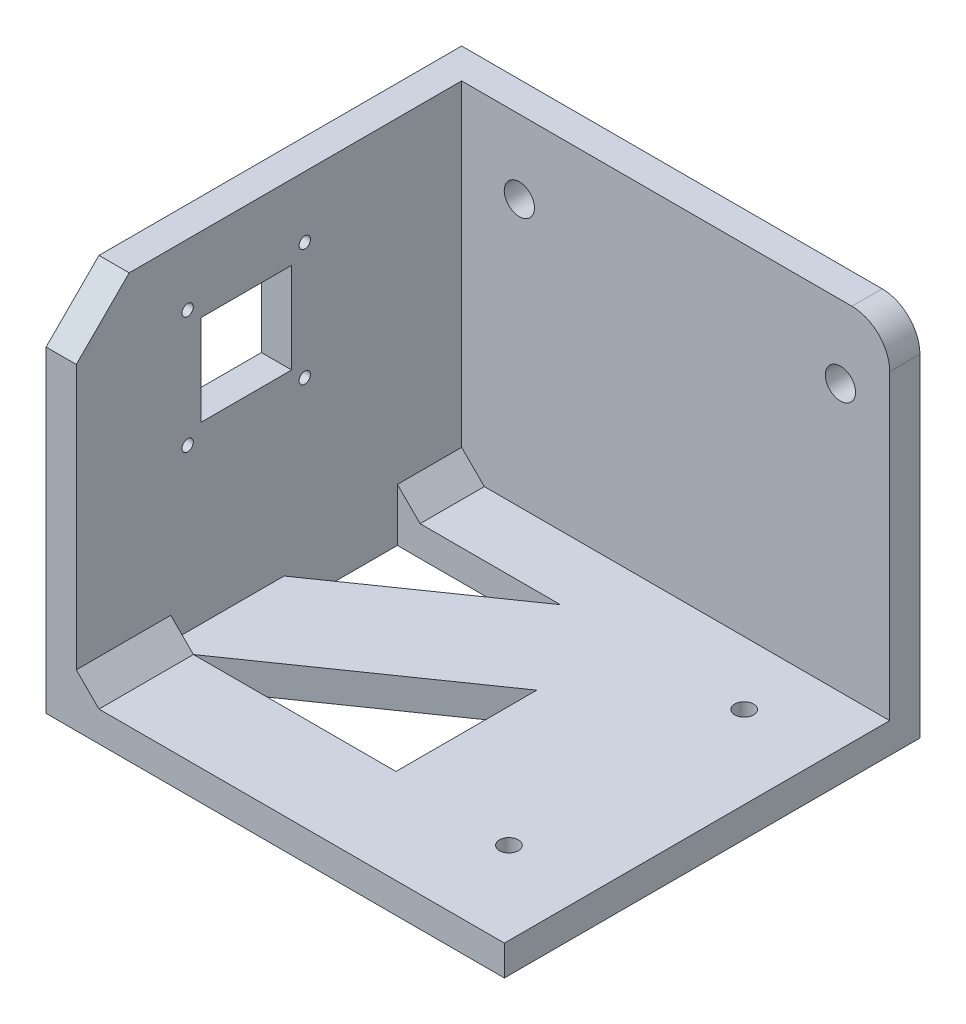
from build123d import *

# Parameters (mm, degrees)
SKETCH2_W            = 45
SKETCH2_H            = 45
BOSS_EXTRUDE1_DEPTH  = 4
SKETCH3_R            = 0.75
CUT_EXTRUDE1_DEPTH   = 5
SKETCH4_W            = 12
SKETCH4_H            = 12
CUT_EXTRUDE2_DEPTH   = 5
SKETCH5_W            = 55
SKETCH5_H            = 4
BOSS_EXTRUDE2_DEPTH  = 60.654134022
SKETCH7_W            = 4
SKETCH7_H            = 49
BOSS_EXTRUDE3_DEPTH  = 10
CUT_EXTRUDE6_DEPTH   = 5
BOSS_EXTRUDE4_DEPTH  = 55
SKETCH12_W           = 29.80716229
SKETCH12_H           = 30
CUT_EXTRUDE7_DEPTH   = 50
SCALE2_SCALE         = 2
BOSS_EXTRUDE10_DEPTH = 8
SKETCH29_W           = 121.308268044
SKETCH29_H           = 8
BOSS_EXTRUDE11_DEPTH = 98
SKETCH30_R           = 2.5
CUT_EXTRUDE8_DEPTH   = 98
SKETCH31_R           = 2.5
CUT_EXTRUDE9_DEPTH   = 98
SKETCH32_R           = 4
CUT_EXTRUDE10_DEPTH  = 98
FILLET1_R            = 10


with BuildPart() as part:
    # Sketch2 → Boss-Extrude1 (new body)
    with BuildSketch(Plane(origin=(0, 0, 0), x_dir=(0, 0, -1), z_dir=(1, 0, 0))):
        Rectangle(SKETCH2_W, SKETCH2_H)
    extrude(amount=BOSS_EXTRUDE1_DEPTH)

    # Sketch3 → Cut-Extrude1 (cut)
    with BuildSketch(Plane(origin=(4, 0, 0), x_dir=(0, 0, -1), z_dir=(1, 0, 0))):
        with Locations((-7.762444982, 14.365)):
            Circle(SKETCH3_R)
        with Locations((-7.762444982, -1.135)):
            Circle(SKETCH3_R)
        with Locations((7.737555018, -1.135)):
            Circle(SKETCH3_R)
        with Locations((7.737555018, 14.365)):
            Circle(SKETCH3_R)
    extrude(amount=-CUT_EXTRUDE1_DEPTH, mode=Mode.SUBTRACT)

    # Sketch4 → Cut-Extrude2 (cut)
    with BuildSketch(Plane(origin=(4, 0, 0), x_dir=(0, 0, -1), z_dir=(1, 0, 0))):
        with Locations((0.001587774, 6.615)):
            Rectangle(SKETCH4_W, SKETCH4_H)
    extrude(amount=-CUT_EXTRUDE2_DEPTH, mode=Mode.SUBTRACT)

    # Sketch5 → Boss-Extrude2 (add)
    with BuildSketch(Plane(origin=(0, 0, 0), x_dir=(0, 0, -1), z_dir=(1, 0, 0))):
        with Locations((5, -24.5)):
            Rectangle(SKETCH5_W, SKETCH5_H)
    extrude(amount=BOSS_EXTRUDE2_DEPTH)

    # Sketch7 → Boss-Extrude3 (add)
    with BuildSketch(Plane(origin=(0, 0, -22.5), x_dir=(-1, 0, 0), z_dir=(0, 0, -1))):
        with Locations((-2, -2)):
            Rectangle(SKETCH7_W, SKETCH7_H)
    extrude(amount=BOSS_EXTRUDE3_DEPTH)

    # Sketch9 → Cut-Extrude6 (cut, through all)
    with BuildSketch(Plane(origin=(4, 0, 0), x_dir=(0, 0, -1), z_dir=(1, 0, 0))):
        Polygon((-22.5, 15.5), (-22.5, 22.5), (-15.5, 22.5), align=None)
    extrude(amount=-CUT_EXTRUDE6_DEPTH, mode=Mode.SUBTRACT)

    # Sketch11 → Boss-Extrude4 (add)
    with BuildSketch(Plane.XY.offset(22.5)):
        Polygon((4, -19.5), (7, -22.5), (4, -22.5), align=None)
    extrude(amount=-BOSS_EXTRUDE4_DEPTH)

    # Sketch12 → Cut-Extrude7 (cut, through all)
    with BuildSketch(Plane.XZ.offset(26.5)):
        with Locations((18.903581145, -5)):
            Rectangle(SKETCH12_W, SKETCH12_H)
    extrude(amount=-CUT_EXTRUDE7_DEPTH, mode=Mode.SUBTRACT)


with BuildPart() as part_1:
    # Scale2: scaled about (18.662210537, -12.9832523, -5.287627144)
    add(part.part.scale(SCALE2_SCALE).moved(Location((-18.662210537, 12.9832523, 5.287627144))))

    # Sketch21 → Boss-Extrude10 (add)
    with BuildSketch(Plane(origin=(0, -40.0167477, 0), x_dir=(-1, 0, 0), z_dir=(0, -1, 0))):
        Polygon((10.662210537, -25.287627144), (4.662210537, -25.287627144), (-48.952114042, 11.991594358), (-48.952114042, 34.712372856), (-32.483264947, 34.712372856), (10.662210537, 4.712372856), align=None)
    extrude(amount=-BOSS_EXTRUDE10_DEPTH)

    # Sketch29 → Boss-Extrude11 (add)
    with BuildSketch(Plane.XZ.offset(40.0167477)):
        with Locations((41.991923485, -55.712372856)):
            Rectangle(SKETCH29_W, SKETCH29_H)
    extrude(amount=-BOSS_EXTRUDE11_DEPTH)

    # Sketch30 → Cut-Extrude8 (cut)
    with BuildSketch(Plane(origin=(0, -32.0167477, 0), x_dir=(1, 0, 0), z_dir=(0, 1, 0))):
        with Locations((80.823761479, -27.259651972)):
            Circle(SKETCH30_R)
    extrude(amount=-CUT_EXTRUDE8_DEPTH, mode=Mode.SUBTRACT)

    # Sketch31 → Cut-Extrude9 (cut)
    with BuildSketch(Plane(origin=(0, -32.0167477, 0), x_dir=(1, 0, 0), z_dir=(0, 1, 0))):
        with Locations((80.823761479, 35.016859129)):
            Circle(SKETCH31_R)
    extrude(amount=-CUT_EXTRUDE9_DEPTH, mode=Mode.SUBTRACT)

    # Sketch32 → Cut-Extrude10 (cut)
    with BuildSketch(Plane(origin=(0, 0, -59.712372856), x_dir=(-1, 0, 0), z_dir=(0, 0, -1))):
        with Locations((-89.60887453, 38.7332523)):
            Circle(SKETCH32_R)
        with Locations((-4.609196036, 38.499466475)):
            Circle(SKETCH32_R)
    extrude(amount=-CUT_EXTRUDE10_DEPTH, mode=Mode.SUBTRACT)

    # Fillet1
    fillet1_edges = [part_1.edges().sort_by_distance(p)[0] for p in [
        (102.646057507, 57.9832523, -55.712372856),
    ]]
    fillet(fillet1_edges, radius=FILLET1_R)


solid = part_1.part
